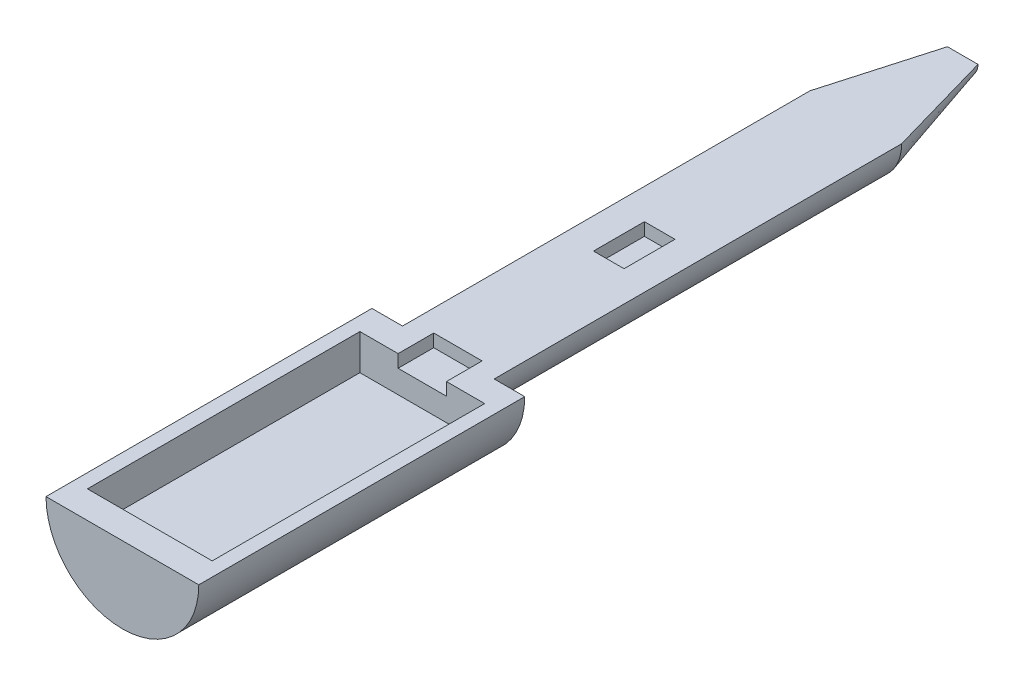
from build123d import *

# Parameters (mm, degrees)
REVOLVE1_ANGLE     = 180
SKETCH3_W          = 24.5
SKETCH3_H          = 53.5
CUT_EXTRUDE1_DEPTH = 7
SKETCH4_W          = 9.5
SKETCH4_H          = 7
CUT_EXTRUDE2_DEPTH = 2.5
SKETCH5_W          = 6
SKETCH5_H          = 10
CUT_EXTRUDE3_DEPTH = 2.5


with BuildPart() as part:
    # Sketch2 → Revolve1 (revolve)
    with BuildSketch(Plane(origin=(0, 0, 0), x_dir=(1, 0, 0), z_dir=(0, 1, 0))):
        Polygon((0, 0), (-15, 0), (-15, 64), (-9, 64), (-9, 144), (-3, 165), (0, 165), align=None)
    revolve(axis=Axis((0, 0, -165), (0, 0, 1)), revolution_arc=REVOLVE1_ANGLE)

    # Sketch3 → Cut-Extrude1 (cut)
    with BuildSketch(Plane(origin=(0, 0, 0), x_dir=(1, 0, 0), z_dir=(0, 1, 0))):
        with Locations((0, 32.132467542)):
            Rectangle(SKETCH3_W, SKETCH3_H)
    extrude(amount=-CUT_EXTRUDE1_DEPTH, mode=Mode.SUBTRACT)

    # Sketch4 → Cut-Extrude2 (cut)
    with BuildSketch(Plane(origin=(0, 0, 0), x_dir=(1, 0, 0), z_dir=(0, 1, 0))):
        with Locations((0, 62.382467542)):
            Rectangle(SKETCH4_W, SKETCH4_H)
    extrude(amount=-CUT_EXTRUDE2_DEPTH, mode=Mode.SUBTRACT)

    # Sketch5 → Cut-Extrude3 (cut)
    with BuildSketch(Plane(origin=(0, 0, 0), x_dir=(1, 0, 0), z_dir=(0, 1, 0))):
        with Locations((0, 100.5)):
            Rectangle(SKETCH5_W, SKETCH5_H)
    extrude(amount=-CUT_EXTRUDE3_DEPTH, mode=Mode.SUBTRACT)


solid = part.part
